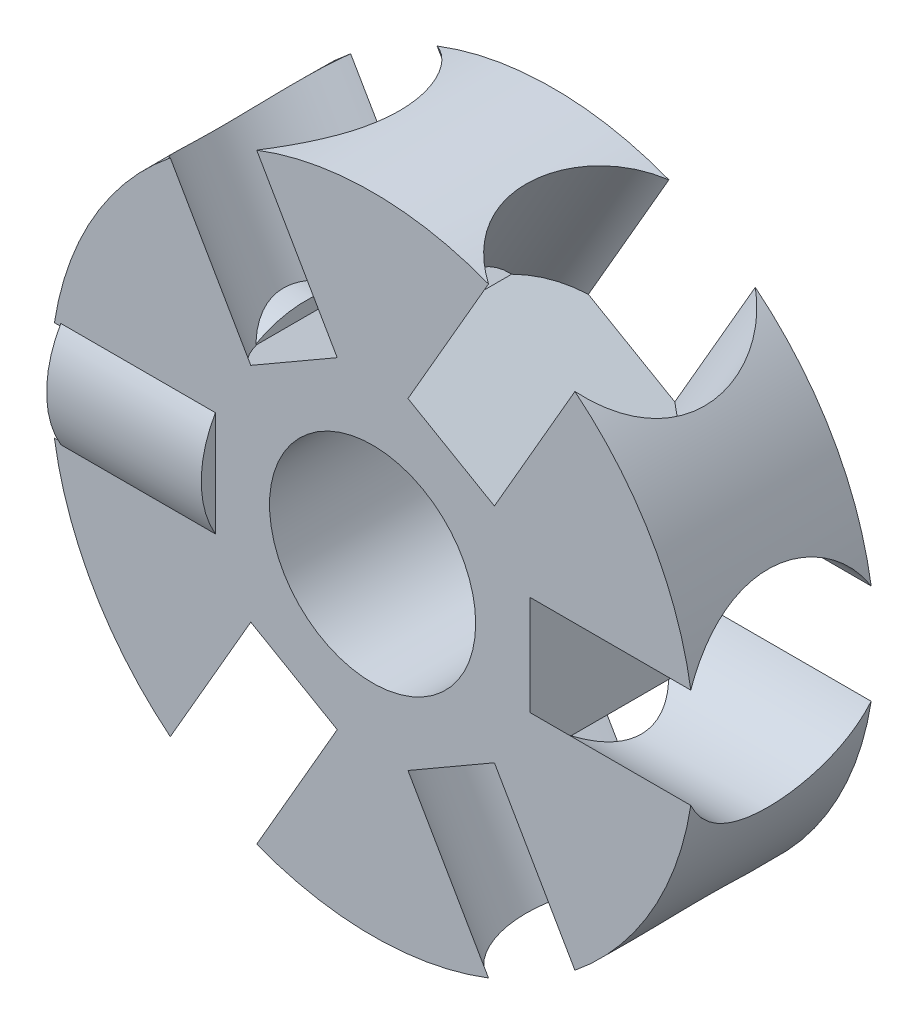
from build123d import *

# Parameters (mm, degrees)
SKETCH1_R           = 12.5
SKETCH1_R_2         = 4
BOSS_EXTRUDE1_DEPTH = 3.5
SKETCH2_R           = 4
CUT_EXTRUDE3_DEPTH  = 6.4
CIRPATTERN1_COUNT   = 6
SKETCH3_R           = 4.05
BOSS_EXTRUDE2_DEPTH = 6


with BuildPart() as part:
    # Sketch1 → Boss-Extrude1 (new, symmetric)
    with BuildSketch(Plane.XY):
        Circle(SKETCH1_R)
        Circle(SKETCH1_R_2, mode=Mode.SUBTRACT)
    extrude(amount=BOSS_EXTRUDE1_DEPTH, both=True)

    # Sketch2 → Cut-Extrude3 (cut)
    with BuildSketch(Plane(origin=(-12.5, -17.193061184, 0), x_dir=(0, -1, 0), z_dir=(1, 0, 0))):
        with Locations((-17.193061184, 0)):
            Circle(SKETCH2_R)
    cut_extrude3 = extrude(amount=CUT_EXTRUDE3_DEPTH, mode=Mode.SUBTRACT)

    # CirPattern1: Cut-Extrude3 ×6 about axis
    cirpattern1_axis = Axis((0, 0, 3.5), (0, 0, 1))
    for i in range(1, CIRPATTERN1_COUNT):
        add(cut_extrude3.rotate(cirpattern1_axis, i * 360 / CIRPATTERN1_COUNT), mode=Mode.SUBTRACT)

    # Sketch3 → Boss-Extrude2 (add)
    with BuildSketch(Plane(origin=(-6.1, 0, 0), x_dir=(0, -1, 0), z_dir=(-1, 0, 0))):
        Circle(SKETCH3_R)
    extrude(amount=BOSS_EXTRUDE2_DEPTH)


solid = part.part
